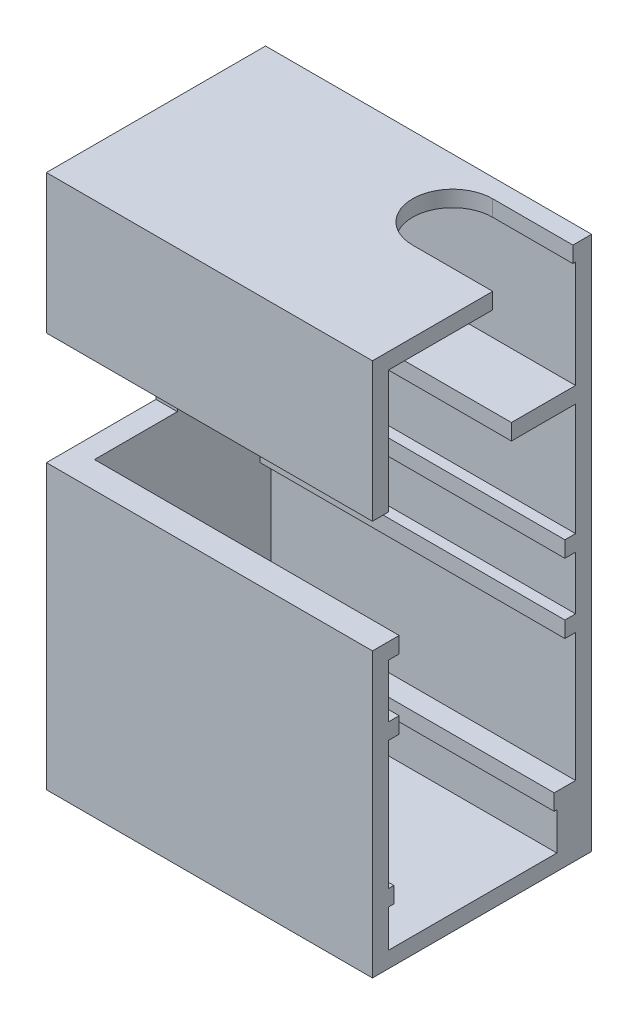
from build123d import *

# Parameters (mm, degrees)
ESQUISSE1_W                          = 61
ESQUISSE1_H                          = 41
BOSS_EXTRU_1_DEPTH                   = 100
ENL_V_MAT_EXTRU_1_DEPTH              = 57
ESQUISSE6_W                          = 58
ESQUISSE6_H                          = 3
BOSS_EXTRU_2_DEPTH                   = 4
ESQUISSE7_W                          = 35
ESQUISSE7_H                          = 3
BOSS_EXTRU_3_DEPTH                   = 6
ESQUISSE11_W                         = 58
ESQUISSE11_H                         = 3
BOSS_EXTRU_4_DEPTH                   = 7
ESQUISSE12_W                         = 59.546555331
ESQUISSE12_H                         = 3
BOSS_EXTRU_5_DEPTH                   = 5
R_P_TITION_LIN_AIRE1_COUNT           = 2
R_P_TITION_LIN_AIRE1_PITCH           = 13
R_P_TITION_LIN_AIRE1_COPY_1_SKETCH_W = 59.546555331
R_P_TITION_LIN_AIRE1_COPY_1_SKETCH_H = 3
R_P_TITION_LIN_AIRE1_COPY_1_DEPTH    = 5
ESQUISSE13_W                         = 15
ESQUISSE13_H                         = 3
BOSS_EXTRU_6_DEPTH                   = 5
R_P_TITION_LIN_AIRE3_COUNT           = 2
R_P_TITION_LIN_AIRE3_PITCH           = 4
ESQUISSE14_W                         = 15
ESQUISSE14_H                         = 7
BOSS_EXTRU_7_DEPTH                   = 16
ESQUISSE15_W                         = 2
ESQUISSE15_H                         = 1
ENL_V_MAT_EXTRU_2_DEPTH              = 14
ENL_V_MAT_EXTRU_3_DEPTH              = 15
ESQUISSE17_W                         = 59.954419869
ESQUISSE17_H                         = 3
BOSS_EXTRU_8_DEPTH                   = 15
ESQUISSE18_W                         = 20.5
ESQUISSE18_H                         = 21
ENL_V_MAT_EXTRU_4_DEPTH              = 62


with BuildPart() as part:
    # Esquisse1 → Boss.-Extru.1 (new body)
    with BuildSketch(Plane(origin=(0, 0, 0), x_dir=(1, 0, 0), z_dir=(0, 1, 0))):
        Rectangle(ESQUISSE1_W, ESQUISSE1_H)
    extrude(amount=BOSS_EXTRU_1_DEPTH)

    # Esquisse3 → Enlèv. mat.-Extru.1 (cut)
    with BuildSketch(Plane(origin=(30.5, 0, 0), x_dir=(0, 0, -1), z_dir=(1, 0, 0))):
        Polygon((17.5, 13), (17.5, 97), (-17.5, 97), (-17.5, 3), (14, 3), (14, 13), align=None)
    extrude(amount=-ENL_V_MAT_EXTRU_1_DEPTH, mode=Mode.SUBTRACT)

    # Esquisse6 → Boss.-Extru.2 (add)
    with BuildSketch(Plane(origin=(0, 0, -20.5), x_dir=(-1, 0, 0), z_dir=(0, 0, -1))):
        with Locations((-1.5, 11.5)):
            Rectangle(ESQUISSE6_W, ESQUISSE6_H)
    boss_extru_2 = extrude(amount=-BOSS_EXTRU_2_DEPTH)

    # Symétrie1: Boss.-Extru.2 across plane
    add(boss_extru_2.mirror(Plane.XY))

    # Esquisse7 → Boss.-Extru.3 (add)
    with BuildSketch(Plane.ZY.offset(30.5)):
        with Locations((0, 11.5)):
            Rectangle(ESQUISSE7_W, ESQUISSE7_H)
    extrude(amount=-BOSS_EXTRU_3_DEPTH)

    # Esquisse11 → Boss.-Extru.4 (add)
    with BuildSketch(Plane(origin=(0, 0, -20.5), x_dir=(-1, 0, 0), z_dir=(0, 0, -1))):
        with Locations((-1.5, 11.5)):
            Rectangle(ESQUISSE11_W, ESQUISSE11_H)
    extrude(amount=-BOSS_EXTRU_4_DEPTH)

    # Esquisse12 → Boss.-Extru.5 (add)
    with BuildSketch(Plane(origin=(0, 0, -20.5), x_dir=(-1, 0, 0), z_dir=(0, 0, -1))):
        with Locations((-0.726722335, 51.5)):
            Rectangle(ESQUISSE12_W, ESQUISSE12_H)
    boss_extru_5 = extrude(amount=-BOSS_EXTRU_5_DEPTH)

    # Symétrie2: Boss.-Extru.5 across plane
    add(boss_extru_5.mirror(Plane.XY))

    # Répétition linéaire1: Boss.-Extru.5 ×2
    with Locations(*[(0, -i * R_P_TITION_LIN_AIRE1_PITCH, 0) for i in range(1, R_P_TITION_LIN_AIRE1_COUNT)]):
        add(boss_extru_5)

    # Répétition linéaire1 copy 1 sketch → Répétition linéaire1 copy 1 (add)
    with BuildSketch(Plane(origin=(0, -13, 20.5), x_dir=(-1, 0, 0), z_dir=(0, 0, 1))):
        with Locations((-0.726722335, -51.5)):
            Rectangle(R_P_TITION_LIN_AIRE1_COPY_1_SKETCH_W, R_P_TITION_LIN_AIRE1_COPY_1_SKETCH_H)
    extrude(amount=-R_P_TITION_LIN_AIRE1_COPY_1_DEPTH)

    # Esquisse13 → Boss.-Extru.6 (add)
    with BuildSketch(Plane.XY.offset(20.5)):
        with Locations((-20, 81.5)):
            Rectangle(ESQUISSE13_W, ESQUISSE13_H)
    boss_extru_6 = extrude(amount=-BOSS_EXTRU_6_DEPTH)

    # Répétition linéaire3: Boss.-Extru.6 ×2
    with Locations(*[(0, i * R_P_TITION_LIN_AIRE3_PITCH, 0) for i in range(1, R_P_TITION_LIN_AIRE3_COUNT)]):
        add(boss_extru_6)

    # Esquisse14 → Boss.-Extru.7 (add)
    with BuildSketch(Plane(origin=(0, 0, -20.5), x_dir=(-1, 0, 0), z_dir=(0, 0, -1))):
        with Locations((20, 83.5)):
            Rectangle(ESQUISSE14_W, ESQUISSE14_H)
    extrude(amount=-BOSS_EXTRU_7_DEPTH)

    # Esquisse15 → Enlèv. mat.-Extru.2 (cut)
    with BuildSketch(Plane(origin=(-12.5, 0, 0), x_dir=(0, 0, -1), z_dir=(1, 0, 0))):
        with Locations((4.5, 83.5)):
            Rectangle(ESQUISSE15_W, ESQUISSE15_H)
    extrude(amount=-ENL_V_MAT_EXTRU_2_DEPTH, mode=Mode.SUBTRACT)

    # Esquisse16 → Enlèv. mat.-Extru.3 (cut)
    with BuildSketch(Plane(origin=(0, 100, 0), x_dir=(1, 0, 0), z_dir=(0, 1, 0))):
        with BuildLine():
            Line((15.5, 2), (30.5, 2))
            Line((30.5, 2), (30.5, 17))
            Line((30.5, 17), (15.5, 17))
            ThreePointArc((15.5, 17), (8, 9.5), (15.5, 2))
        make_face()
    extrude(amount=-ENL_V_MAT_EXTRU_3_DEPTH, mode=Mode.SUBTRACT)

    # Esquisse17 → Boss.-Extru.8 (add)
    with BuildSketch(Plane(origin=(0, 0, -20.5), x_dir=(-1, 0, 0), z_dir=(0, 0, -1))):
        with Locations((-0.522790066, 75.5)):
            Rectangle(ESQUISSE17_W, ESQUISSE17_H)
    extrude(amount=-BOSS_EXTRU_8_DEPTH)

    # Esquisse18 → Enlèv. mat.-Extru.4 (cut, through all)
    with BuildSketch(Plane(origin=(30.5, 0, 0), x_dir=(0, 0, -1), z_dir=(1, 0, 0))):
        with Locations((-10.25, 63.5)):
            Rectangle(ESQUISSE18_W, ESQUISSE18_H)
    extrude(amount=-ENL_V_MAT_EXTRU_4_DEPTH, mode=Mode.SUBTRACT)


solid = part.part
